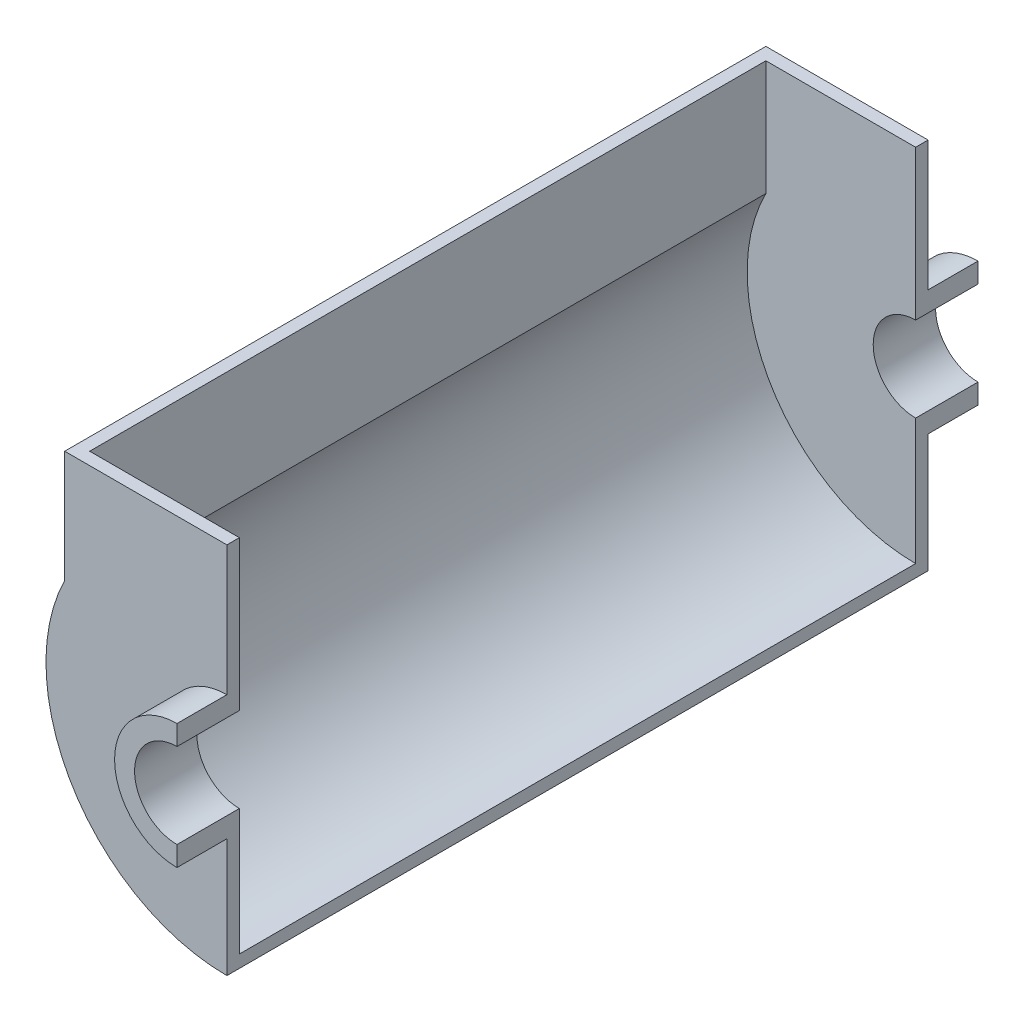
from build123d import *

# Parameters (mm, degrees)
BOSS_EXTRUDE1_DEPTH      = 20
BOSS_EXTRUDE1_DEPTH_BACK = 5
BOSS_EXTRUDE2_DEPTH      = 5
BOSS_EXTRUDE3_DEPTH      = 271


with BuildPart() as part:
    # Sketch2 → Boss-Extrude1 (new body, two sides)
    with BuildSketch(Plane.XY) as boss_extrude1_sk:
        with BuildLine():
            Line((0, 25), (0, 17))
            ThreePointArc((0, 17), (-17, 0), (0, -17))
            Line((0, -17), (0, -25))
            ThreePointArc((0, -25), (-25, 0), (0, 25))
        make_face()
    extrude(amount=BOSS_EXTRUDE1_DEPTH)
    extrude(boss_extrude1_sk.sketch, amount=-BOSS_EXTRUDE1_DEPTH_BACK)

    # Sketch3 → Boss-Extrude2 (add)
    with BuildSketch(Plane.XY):
        with BuildLine():
            Line((0, 25), (0, 77))
            Line((0, 77), (-65, 77))
            Line((-65, 77), (-65, 32.113081447))
            ThreePointArc((-65, 32.113081447), (-61.581037686, -38.262590053), (0, -72.5))
            Line((0, -72.5), (0, -25))
            ThreePointArc((0, -25), (-25, 0), (0, 25))
        make_face()
    extrude(amount=-BOSS_EXTRUDE2_DEPTH)


with BuildPart() as body_2:
    # Mirror3: mirrored copy
    add(part.part.mirror(Plane.XY.offset(-140.5)))


with BuildPart() as part_1:
    add(part.part)

    add(body_2.part)  # Boss-Extrude3 merges body 2
    # Sketch6 → Boss-Extrude3 (add)
    with BuildSketch(Plane(origin=(0, 0, -5), x_dir=(-1, 0, 0), z_dir=(0, 0, -1))):
        with BuildLine():
            Line((65, 77), (65, 32.113081447))
            ThreePointArc((65, 32.113081447), (61.581037686, -38.262590053), (0, -72.5))
            Line((0, -72.5), (0, -67.5))
            ThreePointArc((0, -67.5), (57.634938288, -35.134938288), (60, 30.923292192))
            Line((60, 30.923292192), (60, 77))
            Line((60, 77), (65, 77))
        make_face()
    extrude(amount=BOSS_EXTRUDE3_DEPTH)


solid = part_1.part
